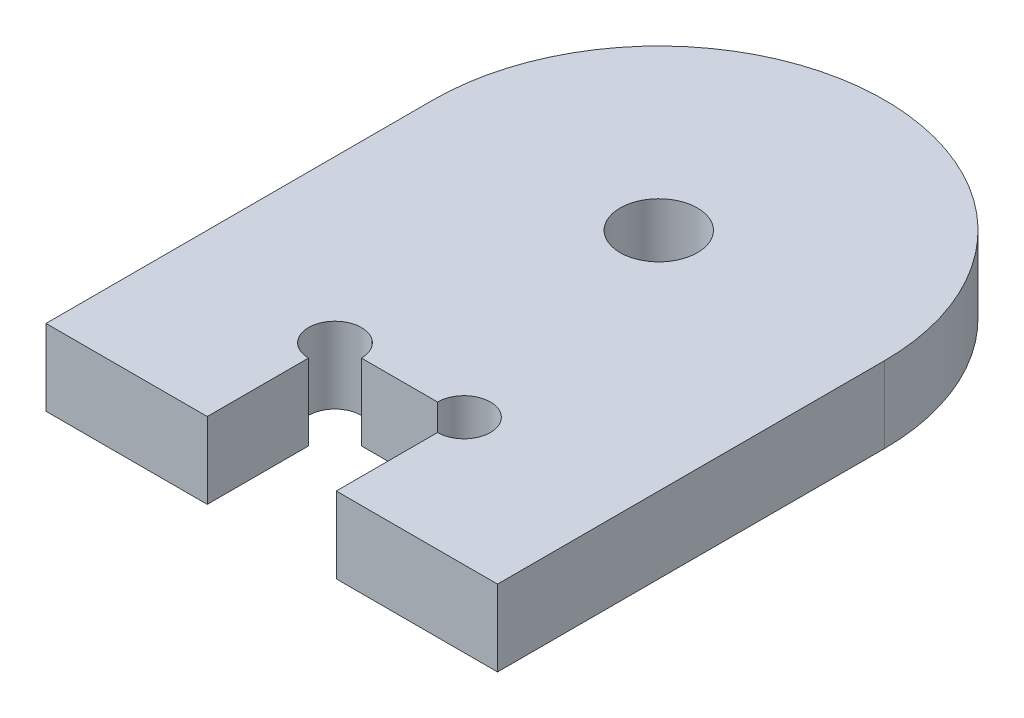
from build123d import *

# Parameters (mm, degrees)
SKETCH1_R           = 3
BOSS_EXTRUDE1_DEPTH = 5.9
CUT_EXTRUDE1_REACH  = 7.9
SKETCH2_W           = 10
SKETCH2_H           = 11.8
SKETCH3_W           = 12.5
SKETCH3_H           = 5.9
BOSS_EXTRUDE2_DEPTH = 5
CUT_EXTRUDE2_REACH  = 7.9
SKETCH4_R           = 2.05


with BuildPart() as part:
    # Sketch1 → Boss-Extrude1 (new body)
    with BuildSketch(Plane(origin=(0, 0, 0), x_dir=(1, 0, 0), z_dir=(0, 1, 0))):
        with BuildLine():
            ThreePointArc((17.5, 12.5), (0, 30), (-17.5, 12.5))
            Line((-17.5, 12.5), (-17.5, -12.5))
            Line((-17.5, -12.5), (17.5, -12.5))
            Line((17.5, -12.5), (17.5, 12.5))
        make_face()
        with Locations((0, 12.5)):
            Circle(SKETCH1_R, mode=Mode.SUBTRACT)
    extrude(amount=BOSS_EXTRUDE1_DEPTH)

    # Sketch2 → Cut-Extrude1 (cut, up to next)
    with BuildSketch(Plane(origin=(0, 5.9, 0), x_dir=(1, 0, 0), z_dir=(0, 1, 0)), mode=Mode.PRIVATE) as cut_extrude1_sk1:
        with Locations((0, -13.5)):
            Rectangle(SKETCH2_W, SKETCH2_H)
    cut_extrude1_tool1 = extrude(cut_extrude1_sk1.sketch, amount=-CUT_EXTRUDE1_REACH, mode=Mode.PRIVATE) & part.part
    add(cut_extrude1_tool1.solids().sort_by_distance((0, 5.9, 13.5))[0], mode=Mode.SUBTRACT)

    # Sketch3 → Boss-Extrude2 (add)
    with BuildSketch(Plane.XY.offset(12.5)):
        with Locations((-11.25, 2.95)):
            Rectangle(SKETCH3_W, SKETCH3_H)
        with Locations((11.25, 2.95)):
            Rectangle(SKETCH3_W, SKETCH3_H)
    extrude(amount=BOSS_EXTRUDE2_DEPTH)

    # Sketch4 → Cut-Extrude2 (cut, up to next)
    with BuildSketch(Plane(origin=(0, 5.9, 0), x_dir=(1, 0, 0), z_dir=(0, 1, 0)), mode=Mode.PRIVATE) as cut_extrude2_sk1:
        with Locations((-5, -7.6)):
            Circle(SKETCH4_R)
    cut_extrude2_tool1 = extrude(cut_extrude2_sk1.sketch, amount=-CUT_EXTRUDE2_REACH, mode=Mode.PRIVATE) & part.part
    add(cut_extrude2_tool1.solids().sort_by_distance((-5, 5.9, 7.6))[0], mode=Mode.SUBTRACT)
    # Sketch4 → Cut-Extrude2 (cut, up to next)
    with BuildSketch(Plane(origin=(0, 5.9, 0), x_dir=(1, 0, 0), z_dir=(0, 1, 0)), mode=Mode.PRIVATE) as cut_extrude2_sk2:
        with Locations((5, -7.6)):
            Circle(SKETCH4_R)
    cut_extrude2_tool2 = extrude(cut_extrude2_sk2.sketch, amount=-CUT_EXTRUDE2_REACH, mode=Mode.PRIVATE) & part.part
    add(cut_extrude2_tool2.solids().sort_by_distance((5, 5.9, 7.6))[0], mode=Mode.SUBTRACT)


solid = part.part
